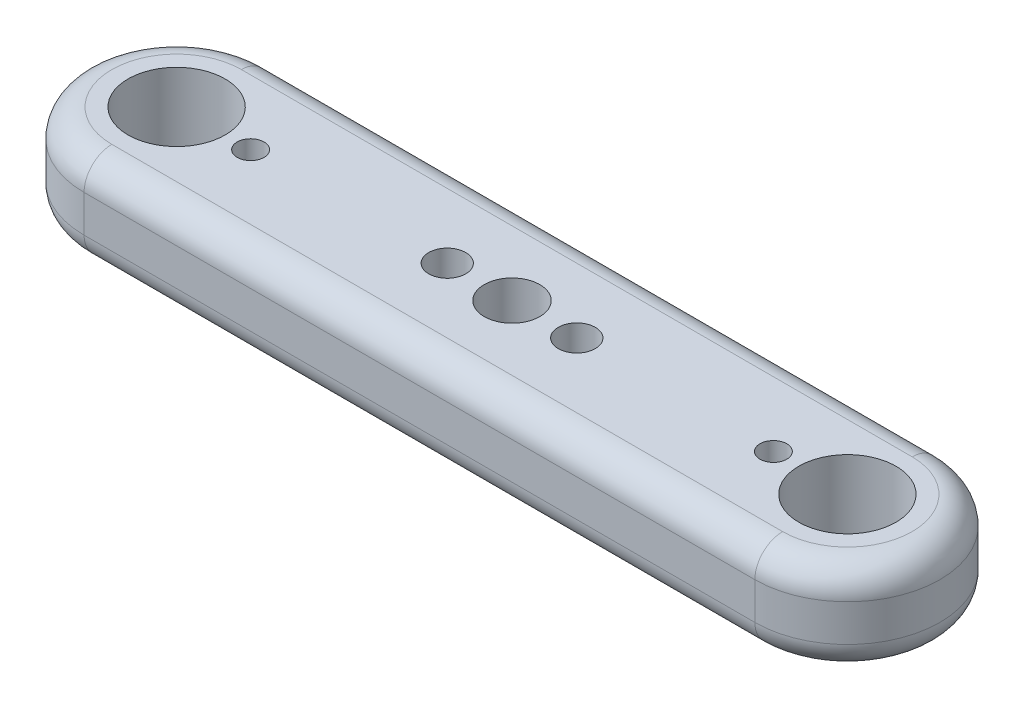
from build123d import *

# Parameters (mm, degrees)
SKETCH2_R           = 5
BOSS_EXTRUDE1_DEPTH = 10
FILLET1_R           = 3
BOSS_EXTRUDE2_DEPTH = 10
SKETCH5_R           = 5
SKETCH5_R_2         = 4.5
BOSS_EXTRUDE3_DEPTH = 10
SKETCH6_R           = 2
CUT_EXTRUDE1_DEPTH  = 10
SKETCH7_R           = 3
CUT_EXTRUDE2_DEPTH  = 10
SKETCH8_R           = 4.65
CUT_EXTRUDE3_DEPTH  = 17
SKETCH9_R           = 4.65
SKETCH9_R_2         = 5.25
CUT_EXTRUDE4_DEPTH  = 10
SKETCH9_3_R         = 1.45
CUT_EXTRUDE5_DEPTH  = 10


with BuildPart() as part:
    # Sketch2 → Boss-Extrude1 (new body)
    with BuildSketch(Plane(origin=(0, 0, 0), x_dir=(1, 0, 0), z_dir=(0, 1, 0))):
        with BuildLine():
            Line((36.25, 10), (-36.25, 10))
            ThreePointArc((-36.25, 10), (-46.25, 0), (-36.25, -10))
            Line((-36.25, -10), (36.25, -10))
            ThreePointArc((36.25, -10), (46.25, 0), (36.25, 10))
        make_face()
        with Locations((-36.25, 0)):
            Circle(SKETCH2_R, mode=Mode.SUBTRACT)
        with BuildLine():
            ThreePointArc((5, 0), (3.535533906, -3.535533906), (0, -5))
            ThreePointArc((0, -5), (-5, 0), (0, 5))
            ThreePointArc((0, 5), (3.535533906, 3.535533906), (5, 0))
        make_face(mode=Mode.SUBTRACT)
        with Locations((36.25, 0)):
            Circle(SKETCH2_R, mode=Mode.SUBTRACT)
    extrude(amount=BOSS_EXTRUDE1_DEPTH)

    # Fillet1
    fillet1_edges = [part.edges().sort_by_distance(p)[0] for p in [
        (46.25, 0, 0),
        (0, 0, 10),
        (0, 10, 10),
        (46.25, 10, 0),
        (0, 10, -10),
        (-46.25, 10, 0),
        (-46.25, 0, 0),
        (0, 0, -10),
    ]]
    fillet(fillet1_edges, radius=FILLET1_R)

    # Sketch3 → Boss-Extrude2 (add)
    with BuildSketch(Plane(origin=(0, 10, 0), x_dir=(1, 0, 0), z_dir=(0, 1, 0))):
        with BuildLine():
            Line((5, 0), (0, 0))
            Line((0, 0), (-5, 0))
            ThreePointArc((-5, 0), (0, -5), (5, 0))
        make_face()
        with BuildLine():
            Line((-5, 0), (0, 0))
            Line((0, 0), (5, 0))
            ThreePointArc((5, 0), (0, 5), (-5, 0))
        make_face()
    extrude(amount=-BOSS_EXTRUDE2_DEPTH)

    # Sketch5 → Boss-Extrude3 (add)
    with BuildSketch(Plane(origin=(0, 10, 0), x_dir=(1, 0, 0), z_dir=(0, 1, 0))):
        with Locations((-36.25, 0)):
            Circle(SKETCH5_R)
        with Locations((-36.25, 0)):
            Circle(SKETCH5_R_2, mode=Mode.SUBTRACT)
        with Locations((36.25, 0)):
            Circle(SKETCH5_R)
        with Locations((36.25, 0)):
            Circle(SKETCH5_R_2, mode=Mode.SUBTRACT)
    extrude(amount=-BOSS_EXTRUDE3_DEPTH)

    # Sketch6 → Cut-Extrude1 (cut)
    with BuildSketch(Plane(origin=(0, 10, 0), x_dir=(1, 0, 0), z_dir=(0, 1, 0))):
        with Locations((-7, 0)):
            Circle(SKETCH6_R)
        with Locations((7, 0)):
            Circle(SKETCH6_R)
    extrude(amount=-CUT_EXTRUDE1_DEPTH, mode=Mode.SUBTRACT)

    # Sketch7 → Cut-Extrude2 (cut)
    with BuildSketch(Plane(origin=(0, 10, 0), x_dir=(1, 0, 0), z_dir=(0, 1, 0))):
        Circle(SKETCH7_R)
    extrude(amount=-CUT_EXTRUDE2_DEPTH, mode=Mode.SUBTRACT)

    # Sketch8 → Cut-Extrude3 (cut)
    with BuildSketch(Plane(origin=(0, 10, 0), x_dir=(1, 0, 0), z_dir=(0, 1, 0))):
        with Locations((-36.25, 0)):
            Circle(SKETCH8_R)
        with Locations((36.25, 0)):
            Circle(SKETCH8_R)
    extrude(amount=-CUT_EXTRUDE3_DEPTH, mode=Mode.SUBTRACT)

    # Sketch9 → Cut-Extrude4 (cut)
    with BuildSketch(Plane(origin=(0, 10, 0), x_dir=(1, 0, 0), z_dir=(0, 1, 0))):
        with Locations((-36.25, 0)):
            Circle(SKETCH9_R)
        with Locations((36.25, 0)):
            Circle(SKETCH9_R)
        with Locations((-36.25, 0)):
            Circle(SKETCH9_R_2)
        with Locations((-36.25, 0)):
            Circle(SKETCH9_R, mode=Mode.SUBTRACT)
        with Locations((36.25, 0)):
            Circle(SKETCH9_R_2)
        with Locations((36.25, 0)):
            Circle(SKETCH9_R, mode=Mode.SUBTRACT)
    extrude(amount=-CUT_EXTRUDE4_DEPTH, mode=Mode.SUBTRACT)

    # Sketch9_3 → Cut-Extrude5 (cut)
    with BuildSketch(Plane(origin=(0, 10, 0), x_dir=(1, 0, 0), z_dir=(0, 1, 0))):
        with Locations((-28.25, 0)):
            Circle(SKETCH9_3_R)
        with Locations((28.25, 0)):
            Circle(SKETCH9_3_R)
    extrude(amount=-CUT_EXTRUDE5_DEPTH, mode=Mode.SUBTRACT)


solid = part.part
